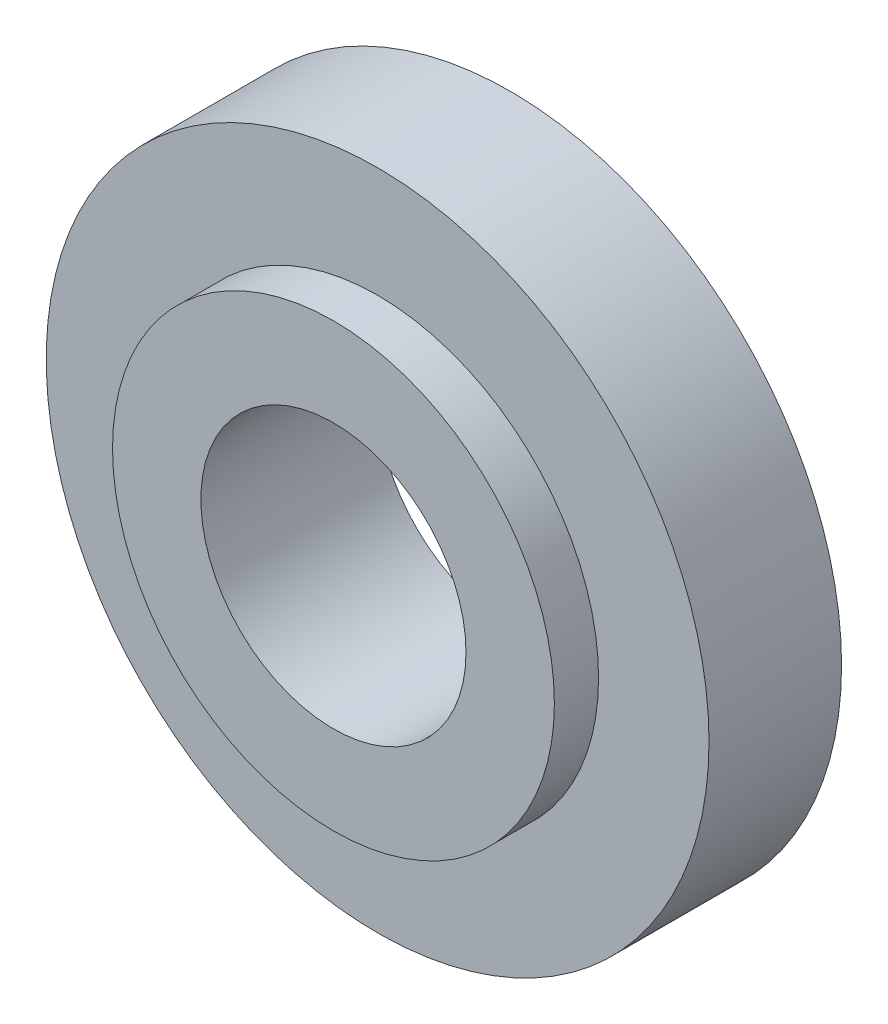
from build123d import *

# Parameters (mm, degrees)
SKETCH1_R               = 3.75
BOSS_EXTRUDE2_DEPTH     = 1.5
SKETCH2_R               = 2.5
BOSS_EXTRUDE3_DEPTH     = 0.5
SKETCH3_R               = 1.5
CUT_EXTRUDE2_DEPTH      = 1
CUT_EXTRUDE2_DEPTH_BACK = 3


with BuildPart() as part:
    # Sketch1 → Boss-Extrude2 (new body)
    with BuildSketch(Plane.XY):
        Circle(SKETCH1_R)
    extrude(amount=BOSS_EXTRUDE2_DEPTH)

    # Sketch2 → Boss-Extrude3 (add)
    with BuildSketch(Plane.XY.offset(1.5)):
        Circle(SKETCH2_R)
    extrude(amount=BOSS_EXTRUDE3_DEPTH)

    # Sketch3 → Cut-Extrude2 (cut, two sides)
    with BuildSketch(Plane.XY.offset(2)) as cut_extrude2_sk:
        Circle(SKETCH3_R)
    extrude(amount=CUT_EXTRUDE2_DEPTH, mode=Mode.SUBTRACT)
    extrude(cut_extrude2_sk.sketch, amount=-CUT_EXTRUDE2_DEPTH_BACK, mode=Mode.SUBTRACT)


solid = part.part
